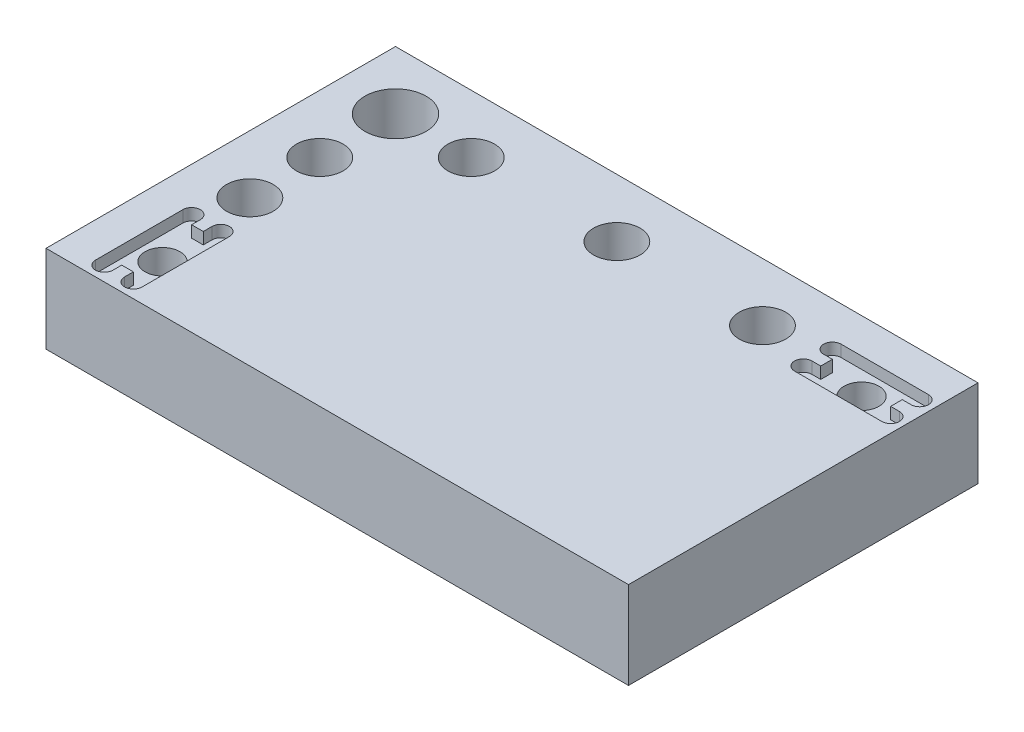
from build123d import *

# Parameters (mm, degrees)
SKETCH1_W             = 100
SKETCH1_H             = 60
BOSS_EXTRUDE1_DEPTH   = 15
CUT_EXTRUDE1_REACH    = 17
SKETCH4_R             = 3
SKETCH5_R             = 5.25
CUT_EXTRUDE2_DEPTH    = 7.7
CUT_EXTRUDE3_REACH    = 17
SKETCH6_R             = 4
CUT_EXTRUDE4_DEPTH    = 4
CUT_EXTRUDE5_REACH    = 17
SKETCH8_R             = 3
CUT_EXTRUDE6_DEPTH    = 2
M3_TAPPED_HOLE1_D     = 2.5
M3_TAPPED_HOLE1_DEPTH = 10
M3_TAPPED_HOLE1_TIP   = 0.751075774


with BuildPart() as part:
    # Sketch1 → Boss-Extrude1 (new body)
    with BuildSketch(Plane(origin=(0, 0, 0), x_dir=(1, 0, 0), z_dir=(0, 1, 0))):
        Rectangle(SKETCH1_W, SKETCH1_H)
    extrude(amount=BOSS_EXTRUDE1_DEPTH)

    # Sketch4 → Cut-Extrude1 (cut, up to next)
    with BuildSketch(Plane(origin=(0, 15, 0), x_dir=(1, 0, 0), z_dir=(0, 1, 0)), mode=Mode.PRIVATE) as cut_extrude1_sk1:
        with Locations((-40, 20)):
            Circle(SKETCH4_R)
    cut_extrude1_tool1 = extrude(cut_extrude1_sk1.sketch, amount=-CUT_EXTRUDE1_REACH, mode=Mode.PRIVATE) & part.part
    add(cut_extrude1_tool1.solids().sort_by_distance((-40, 15, -20))[0], mode=Mode.SUBTRACT)

    # Sketch5 → Cut-Extrude2 (cut)
    with BuildSketch(Plane(origin=(0, 15, 0), x_dir=(1, 0, 0), z_dir=(0, 1, 0))):
        with Locations((-40, 20)):
            Circle(SKETCH5_R)
    extrude(amount=-CUT_EXTRUDE2_DEPTH, mode=Mode.SUBTRACT)

    # Sketch6 → Cut-Extrude3 (cut, up to next)
    with BuildSketch(Plane(origin=(0, 15, 0), x_dir=(1, 0, 0), z_dir=(0, 1, 0)), mode=Mode.PRIVATE) as cut_extrude3_sk1:
        with Locations((-40, 7)):
            Circle(SKETCH6_R)
    cut_extrude3_tool1 = extrude(cut_extrude3_sk1.sketch, amount=-CUT_EXTRUDE3_REACH, mode=Mode.PRIVATE) & part.part
    add(cut_extrude3_tool1.solids().sort_by_distance((-40, 15, -7))[0], mode=Mode.SUBTRACT)
    # Sketch6 → Cut-Extrude3 (cut, up to next)
    with BuildSketch(Plane(origin=(0, 15, 0), x_dir=(1, 0, 0), z_dir=(0, 1, 0)), mode=Mode.PRIVATE) as cut_extrude3_sk2:
        with Locations((-40, -5)):
            Circle(SKETCH6_R)
    cut_extrude3_tool2 = extrude(cut_extrude3_sk2.sketch, amount=-CUT_EXTRUDE3_REACH, mode=Mode.PRIVATE) & part.part
    add(cut_extrude3_tool2.solids().sort_by_distance((-40, 15, 5))[0], mode=Mode.SUBTRACT)
    # Sketch6 → Cut-Extrude3 (cut, up to next)
    with BuildSketch(Plane(origin=(0, 15, 0), x_dir=(1, 0, 0), z_dir=(0, 1, 0)), mode=Mode.PRIVATE) as cut_extrude3_sk3:
        with Locations((-27, 20)):
            Circle(SKETCH6_R)
    cut_extrude3_tool3 = extrude(cut_extrude3_sk3.sketch, amount=-CUT_EXTRUDE3_REACH, mode=Mode.PRIVATE) & part.part
    add(cut_extrude3_tool3.solids().sort_by_distance((-27, 15, -20))[0], mode=Mode.SUBTRACT)
    # Sketch6 → Cut-Extrude3 (cut, up to next)
    with BuildSketch(Plane(origin=(0, 15, 0), x_dir=(1, 0, 0), z_dir=(0, 1, 0)), mode=Mode.PRIVATE) as cut_extrude3_sk4:
        with Locations((-2, 20)):
            Circle(SKETCH6_R)
    cut_extrude3_tool4 = extrude(cut_extrude3_sk4.sketch, amount=-CUT_EXTRUDE3_REACH, mode=Mode.PRIVATE) & part.part
    add(cut_extrude3_tool4.solids().sort_by_distance((-2, 15, -20))[0], mode=Mode.SUBTRACT)
    # Sketch6 → Cut-Extrude3 (cut, up to next)
    with BuildSketch(Plane(origin=(0, 15, 0), x_dir=(1, 0, 0), z_dir=(0, 1, 0)), mode=Mode.PRIVATE) as cut_extrude3_sk5:
        with Locations((23, 20)):
            Circle(SKETCH6_R)
    cut_extrude3_tool5 = extrude(cut_extrude3_sk5.sketch, amount=-CUT_EXTRUDE3_REACH, mode=Mode.PRIVATE) & part.part
    add(cut_extrude3_tool5.solids().sort_by_distance((23, 15, -20))[0], mode=Mode.SUBTRACT)

    # Sketch7 → Cut-Extrude4 (cut)
    with BuildSketch(Plane.XZ):
        with BuildLine():
            Line((-46, 6.5), (-34, 6.5))
            ThreePointArc((-34, 6.5), (-32.5, 5), (-34, 3.5))
            Line((-34, 3.5), (-46, 3.5))
            ThreePointArc((-46, 3.5), (-47.5, 5), (-46, 6.5))
        make_face()
        with BuildLine():
            Line((-46, -5.5), (-34, -5.5))
            ThreePointArc((-34, -5.5), (-32.5, -7), (-34, -8.5))
            Line((-34, -8.5), (-46, -8.5))
            ThreePointArc((-46, -8.5), (-47.5, -7), (-46, -5.5))
        make_face()
        with BuildLine():
            Line((-28.5, -26), (-28.5, -14))
            ThreePointArc((-28.5, -14), (-27, -12.5), (-25.5, -14))
            Line((-25.5, -14), (-25.5, -26))
            ThreePointArc((-25.5, -26), (-27, -27.5), (-28.5, -26))
        make_face()
        with BuildLine():
            Line((-3.5, -26), (-3.5, -14))
            ThreePointArc((-3.5, -14), (-2, -12.5), (-0.5, -14))
            Line((-0.5, -14), (-0.5, -26))
            ThreePointArc((-0.5, -26), (-2, -27.5), (-3.5, -26))
        make_face()
        with BuildLine():
            Line((21.5, -26), (21.5, -14))
            ThreePointArc((21.5, -14), (23, -12.5), (24.5, -14))
            Line((24.5, -14), (24.5, -26))
            ThreePointArc((24.5, -26), (23, -27.5), (21.5, -26))
        make_face()
    extrude(amount=-CUT_EXTRUDE4_DEPTH, mode=Mode.SUBTRACT)

    # Sketch8 → Cut-Extrude5 (cut, up to next)
    with BuildSketch(Plane(origin=(0, 15, 0), x_dir=(1, 0, 0), z_dir=(0, 1, 0)), mode=Mode.PRIVATE) as cut_extrude5_sk1:
        with Locations((40, 20)):
            Circle(SKETCH8_R)
    cut_extrude5_tool1 = extrude(cut_extrude5_sk1.sketch, amount=-CUT_EXTRUDE5_REACH, mode=Mode.PRIVATE) & part.part
    add(cut_extrude5_tool1.solids().sort_by_distance((40, 15, -20))[0], mode=Mode.SUBTRACT)
    # Sketch8 → Cut-Extrude5 (cut, up to next)
    with BuildSketch(Plane(origin=(0, 15, 0), x_dir=(1, 0, 0), z_dir=(0, 1, 0)), mode=Mode.PRIVATE) as cut_extrude5_sk2:
        with Locations((-40, -20)):
            Circle(SKETCH8_R)
    cut_extrude5_tool2 = extrude(cut_extrude5_sk2.sketch, amount=-CUT_EXTRUDE5_REACH, mode=Mode.PRIVATE) & part.part
    add(cut_extrude5_tool2.solids().sort_by_distance((-40, 15, 20))[0], mode=Mode.SUBTRACT)

    # Sketch9 → Cut-Extrude6 (cut)
    with BuildSketch(Plane(origin=(0, 15, 0), x_dir=(1, 0, 0), z_dir=(0, 1, 0))):
        with BuildLine():
            Line((-41, -26), (-42.5, -26))
            Line((-42.5, -26), (-42.5, -21.658312395))
            ThreePointArc((-42.5, -21.658312395), (-43, -20), (-42.5, -18.341687605))
            Line((-42.5, -18.341687605), (-42.5, -14))
            Line((-42.5, -14), (-41, -14))
            Line((-41, -14), (-41, -12.5))
            ThreePointArc((-41, -12.5), (-42.5, -11), (-44, -12.5))
            Line((-44, -12.5), (-44, -27.5))
            ThreePointArc((-44, -27.5), (-42.5, -29), (-41, -27.5))
            Line((-41, -27.5), (-41, -26))
        make_face()
        with BuildLine():
            Line((-41, -14), (-41, -17.171572875))
            ThreePointArc((-41, -17.171572875), (-40, -17), (-39, -17.171572875))
            Line((-39, -17.171572875), (-39, -14))
            Line((-39, -14), (-41, -14))
        make_face()
        with BuildLine():
            Line((-42.5, -21.658312395), (-42.5, -26))
            Line((-42.5, -26), (-41, -26))
            Line((-41, -26), (-41, -22.828427125))
            ThreePointArc((-41, -22.828427125), (-41.84520788, -22.365419176), (-42.5, -21.658312395))
        make_face()
        with BuildLine():
            Line((-41, -22.828427125), (-41, -26))
            Line((-41, -26), (-39, -26))
            Line((-39, -26), (-39, -22.828427125))
            ThreePointArc((-39, -22.828427125), (-40, -23), (-41, -22.828427125))
        make_face()
        with BuildLine():
            Line((-39, -22.828427125), (-39, -26))
            Line((-39, -26), (-37.5, -26))
            Line((-37.5, -26), (-37.5, -21.658312395))
            ThreePointArc((-37.5, -21.658312395), (-38.15479212, -22.365419176), (-39, -22.828427125))
        make_face()
        with BuildLine():
            Line((-37.5, -26), (-39, -26))
            Line((-39, -26), (-39, -27.5))
            ThreePointArc((-39, -27.5), (-37.5, -29), (-36, -27.5))
            Line((-36, -27.5), (-36, -12.5))
            ThreePointArc((-36, -12.5), (-37.5, -11), (-39, -12.5))
            Line((-39, -12.5), (-39, -14))
            Line((-39, -14), (-37.5, -14))
            Line((-37.5, -14), (-37.5, -18.341687605))
            ThreePointArc((-37.5, -18.341687605), (-37.127718677, -19.133974596), (-37, -20))
            ThreePointArc((-37, -20), (-37.127718677, -20.866025404), (-37.5, -21.658312395))
            Line((-37.5, -21.658312395), (-37.5, -26))
        make_face()
        with BuildLine():
            Line((-39, -14), (-39, -17.171572875))
            ThreePointArc((-39, -17.171572875), (-38.15479212, -17.634580824), (-37.5, -18.341687605))
            Line((-37.5, -18.341687605), (-37.5, -14))
            Line((-37.5, -14), (-39, -14))
        make_face()
        with BuildLine():
            Line((-42.5, -14), (-42.5, -18.341687605))
            ThreePointArc((-42.5, -18.341687605), (-41.84520788, -17.634580824), (-41, -17.171572875))
            Line((-41, -17.171572875), (-41, -14))
            Line((-41, -14), (-42.5, -14))
        make_face()
        with BuildLine():
            Line((34, 19), (34, 17.5))
            Line((34, 17.5), (38.341687605, 17.5))
            ThreePointArc((38.341687605, 17.5), (37.634580824, 18.15479212), (37.171572875, 19))
            Line((37.171572875, 19), (34, 19))
        make_face()
        with BuildLine():
            ThreePointArc((42.828427125, 19), (42.365419176, 18.15479212), (41.658312395, 17.5))
            Line((41.658312395, 17.5), (46, 17.5))
            Line((46, 17.5), (46, 19))
            Line((46, 19), (42.828427125, 19))
        make_face()
        with BuildLine():
            Line((38.341687605, 17.5), (34, 17.5))
            Line((34, 17.5), (34, 19))
            Line((34, 19), (32.5, 19))
            ThreePointArc((32.5, 19), (31, 17.5), (32.5, 16))
            Line((32.5, 16), (47.5, 16))
            ThreePointArc((47.5, 16), (49, 17.5), (47.5, 19))
            Line((47.5, 19), (46, 19))
            Line((46, 19), (46, 17.5))
            Line((46, 17.5), (41.658312395, 17.5))
            ThreePointArc((41.658312395, 17.5), (40, 17), (38.341687605, 17.5))
        make_face()
        with BuildLine():
            ThreePointArc((41.658312395, 22.5), (42.365419176, 21.84520788), (42.828427125, 21))
            Line((42.828427125, 21), (46, 21))
            Line((46, 21), (46, 22.5))
            Line((46, 22.5), (41.658312395, 22.5))
        make_face()
        with BuildLine():
            ThreePointArc((43, 20), (42.956795679, 19.492694064), (42.828427125, 19))
            Line((42.828427125, 19), (46, 19))
            Line((46, 19), (46, 21))
            Line((46, 21), (42.828427125, 21))
            ThreePointArc((42.828427125, 21), (42.956795679, 20.507305936), (43, 20))
        make_face()
        with BuildLine():
            Line((34, 21), (34, 19))
            Line((34, 19), (37.171572875, 19))
            ThreePointArc((37.171572875, 19), (37, 20), (37.171572875, 21))
            Line((37.171572875, 21), (34, 21))
        make_face()
        with BuildLine():
            Line((34, 22.5), (34, 21))
            Line((34, 21), (37.171572875, 21))
            ThreePointArc((37.171572875, 21), (37.634580824, 21.84520788), (38.341687605, 22.5))
            Line((38.341687605, 22.5), (34, 22.5))
        make_face()
        with BuildLine():
            Line((32.5, 21), (34, 21))
            Line((34, 21), (34, 22.5))
            Line((34, 22.5), (38.341687605, 22.5))
            ThreePointArc((38.341687605, 22.5), (40, 23), (41.658312395, 22.5))
            Line((41.658312395, 22.5), (46, 22.5))
            Line((46, 22.5), (46, 21))
            Line((46, 21), (47.5, 21))
            ThreePointArc((47.5, 21), (49, 22.5), (47.5, 24))
            Line((47.5, 24), (32.5, 24))
            ThreePointArc((32.5, 24), (31, 22.5), (32.5, 21))
        make_face()
    extrude(amount=-CUT_EXTRUDE6_DEPTH, mode=Mode.SUBTRACT)

    # M3 Tapped Hole1
    with Locations(Plane(origin=(0, 0, 0), x_dir=(-1, 0, 0), z_dir=(0, -1, 0))):
        with Locations((28.5, -18), (27.223611076, -13.081475452), (28.5, 2), (-27.742358719, -18), (-27.742358719, 2), (-27.223611076, 13.081475452), (-13.081475452, 27.223611076), (13.081475452, -27.223611076)):
            Hole(M3_TAPPED_HOLE1_D / 2, depth=M3_TAPPED_HOLE1_DEPTH)
            with Locations((0, 0, -(M3_TAPPED_HOLE1_DEPTH + M3_TAPPED_HOLE1_TIP / 2))):  # 118° drill point
                Cone(0, M3_TAPPED_HOLE1_D / 2, M3_TAPPED_HOLE1_TIP, mode=Mode.SUBTRACT)


solid = part.part
